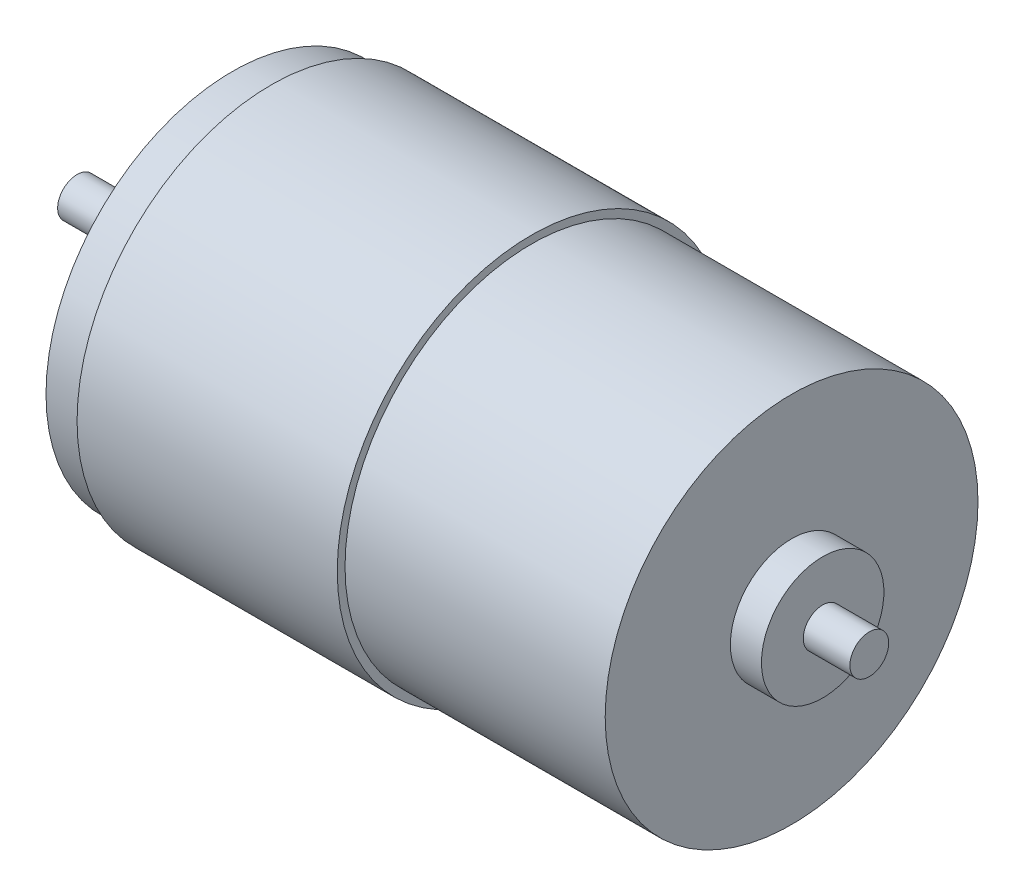
from build123d import *

# Parameters (mm, degrees)
SKETCH_2_R          = 2
SKETCH_2_R_2        = 2.5
CUT_EXTRUDE_1_DEPTH = 2


with BuildPart() as part:
    # 草图1 → 旋转1 (revolve)
    with BuildSketch(Plane(origin=(0, 0, 0), x_dir=(1, 0, 0), z_dir=(0, 1, 0)), mode=Mode.PRIVATE) as revolve_1_sk:
        Polygon((-6.743925692, 2.5), (-6.743925692, 0), (95.256074308, 0), (95.256074308, 2.5), (89.256074308, 2.5), (89.256074308, 7.88455591), (85.256074308, 7.88455591), (85.256074308, 24), (51.756074308, 24), (51.756074308, 25), (18.256074308, 25), (18.256074308, 24), (13.256074308, 24), (13.256074308, 9), (9.256074308, 9), (9.256074308, 2.5), align=None)
    revolve(revolve_1_sk.sketch.rotate(Axis((-8.123537978, 0, 0), (1, 0, 0)), 180), axis=Axis((-8.123537978, 0, 0), (1, 0, 0)))

    # 草图2 → 切除-拉伸1 (cut)
    with BuildSketch(Plane.ZY.offset(-13.256074308)):
        with Locations((0, 14.5)):
            Circle(SKETCH_2_R)
        with Locations(Location((0, -14.5, 0), (0, 0, 180))):
            Circle(SKETCH_2_R)
        with Locations((-16, 0)):
            Circle(SKETCH_2_R_2)
        with Locations(Location((16, 0, 0), (0, 0, 180))):
            Circle(SKETCH_2_R_2)
    extrude(amount=-CUT_EXTRUDE_1_DEPTH, mode=Mode.SUBTRACT)


solid = part.part
